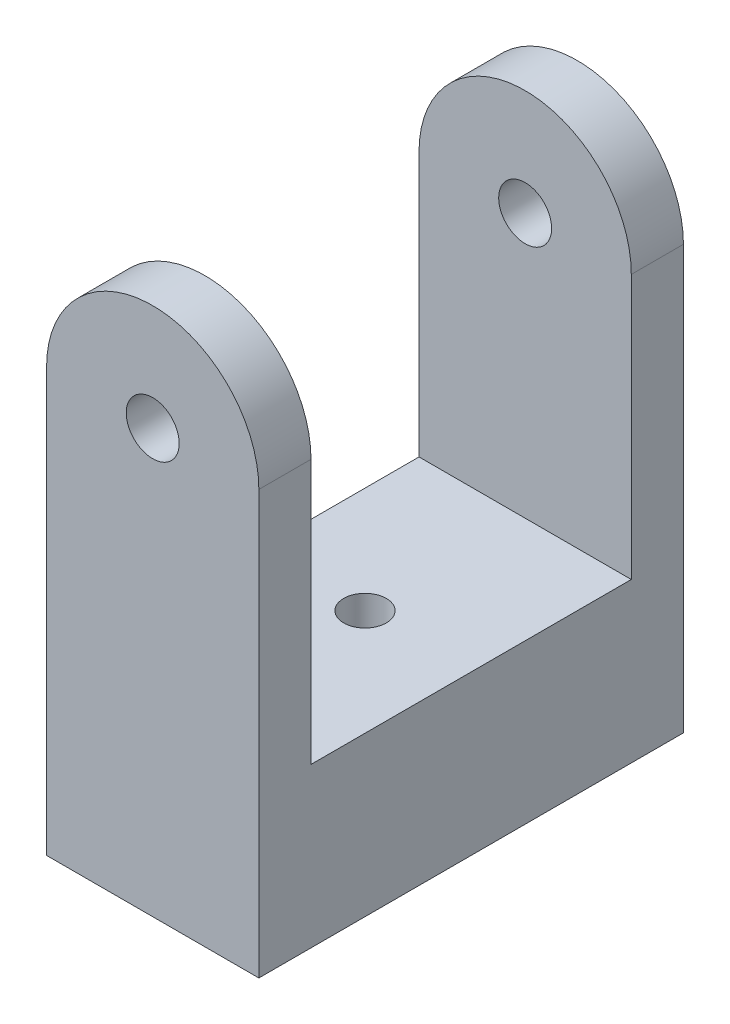
from build123d import *

# Parameters (mm, degrees)
SKETCH3_R               = 3.175
BOSS_EXTRUDE2_DEPTH     = 50.9
SKETCH7_W               = 38.4
SKETCH7_H               = 44.4
CUT_EXTRUDE1_DEPTH      = 26.45
F_1_4_20_TAPPED_HOLE1_D = 5.1054


with BuildPart() as part:
    # Sketch3 → Boss-Extrude2 (new body)
    with BuildSketch(Plane.XY):
        with BuildLine():
            Line((-17.009907165, -36.719884412), (8.440092835, -36.719884412))
            Line((8.440092835, -36.719884412), (8.440092835, 14.005115588))
            ThreePointArc((8.440092835, 14.005115588), (-4.284907165, 26.730115588), (-17.009907165, 14.005115588))
            Line((-17.009907165, 14.005115588), (-17.009907165, -36.719884412))
        make_face()
        with Locations((-4.284907165, 14.005115588)):
            Circle(SKETCH3_R, mode=Mode.SUBTRACT)
    extrude(amount=BOSS_EXTRUDE2_DEPTH)

    # Sketch7 → Cut-Extrude1 (cut, through all)
    with BuildSketch(Plane(origin=(8.440092835, 0, 0), x_dir=(0, 0, -1), z_dir=(1, 0, 0))):
        with Locations((-25.45, 4.530115588)):
            Rectangle(SKETCH7_W, SKETCH7_H)
    extrude(amount=-CUT_EXTRUDE1_DEPTH, mode=Mode.SUBTRACT)

    # 1/4-20 Tapped Hole1 (through all)
    with Locations(Plane(origin=(-4.284907165, -36.719884412, 25.45), x_dir=(0, 0, -1), z_dir=(0, -1, 0))):
        with Locations((0, 0)):
            Hole(F_1_4_20_TAPPED_HOLE1_D / 2)


solid = part.part
